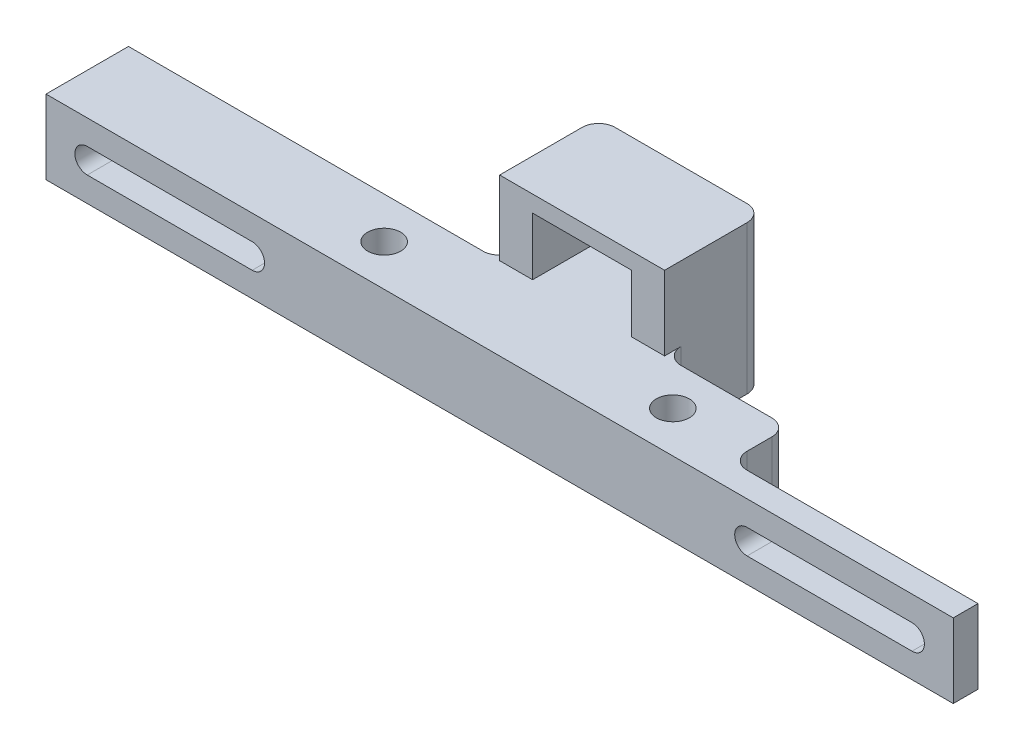
from build123d import *

# Parameters (mm, degrees)
ESBO_O1_W                = 45
ESBO_O1_H                = 9
RESSALTO_EXTRUS_O2_DEPTH = 10
RESSALTO_EXTRUS_O3_DEPTH = 12
ESBO_O2_R                = 2
ESBO_O2_W                = 30
ESBO_O2_H                = 7
CORTE_EXTRUS_O4_DEPTH    = 9
FILETE2_R                = 2


with BuildPart() as part:
    # Esboço1 → Ressalto-extrusão2 (new body)
    with BuildSketch(Plane.XY):
        with Locations((32.5, 0)):
            Rectangle(ESBO_O1_W, ESBO_O1_H)
        with BuildLine():
            ThreePointArc((30, -1.5), (28.5, 0), (30, 1.5))
            Line((30, 1.5), (50, 1.5))
            ThreePointArc((50, 1.5), (51.5, 0), (50, -1.5))
            Line((50, -1.5), (30, -1.5))
        make_face(mode=Mode.SUBTRACT)
        Polygon((6, 4.5), (-6, 4.5), (-10, 4.5), (-10, -4.5), (10, -4.5), (10, 4.5), align=None)
        with Locations((-32.5, 0)):
            Rectangle(ESBO_O1_W, ESBO_O1_H)
        with BuildLine():
            ThreePointArc((-50, -1.5), (-51.5, 0), (-50, 1.5))
            Line((-50, 1.5), (-30, 1.5))
            ThreePointArc((-30, 1.5), (-28.5, 0), (-30, -1.5))
            Line((-30, -1.5), (-50, -1.5))
        make_face(mode=Mode.SUBTRACT)
    extrude(amount=RESSALTO_EXTRUS_O2_DEPTH)

    # Esboço1<5> → Ressalto-extrusão3 (add)
    with BuildSketch(Plane.XY):
        Polygon((6, 4.5), (-6, 4.5), (-10, 4.5), (-10, -4.5), (10, -4.5), (10, 4.5), align=None)
        Polygon((-10, 4.5), (-6, 4.5), (-6, 11.5), (6, 11.5), (6, 4.5), (10, 4.5), (10, 13.5), (-10, 13.5), align=None)
    extrude(amount=-RESSALTO_EXTRUS_O3_DEPTH)

    # Esboço2 → Corte-extrusão4 (cut)
    with BuildSketch(Plane(origin=(0, 4.5, 0), x_dir=(1, 0, 0), z_dir=(0, 1, 0))):
        with Locations((-19, -5)):
            Circle(ESBO_O2_R)
        with Locations((16, -5)):
            Circle(ESBO_O2_R)
        with Locations((40, -3.5)):
            Rectangle(ESBO_O2_W, ESBO_O2_H)
    extrude(amount=-CORTE_EXTRUS_O4_DEPTH, mode=Mode.SUBTRACT)

    # Filete2
    filete2_edges = [part.edges().sort_by_distance(p)[0] for p in [
        (-10, 0, 0),
        (10, 0, 0),
        (-10, 4.5, -12),
        (10, 4.5, -12),
        (25, 0, 0),
        (25, 0, 7),
    ]]
    fillet(filete2_edges, radius=FILETE2_R)


solid = part.part
